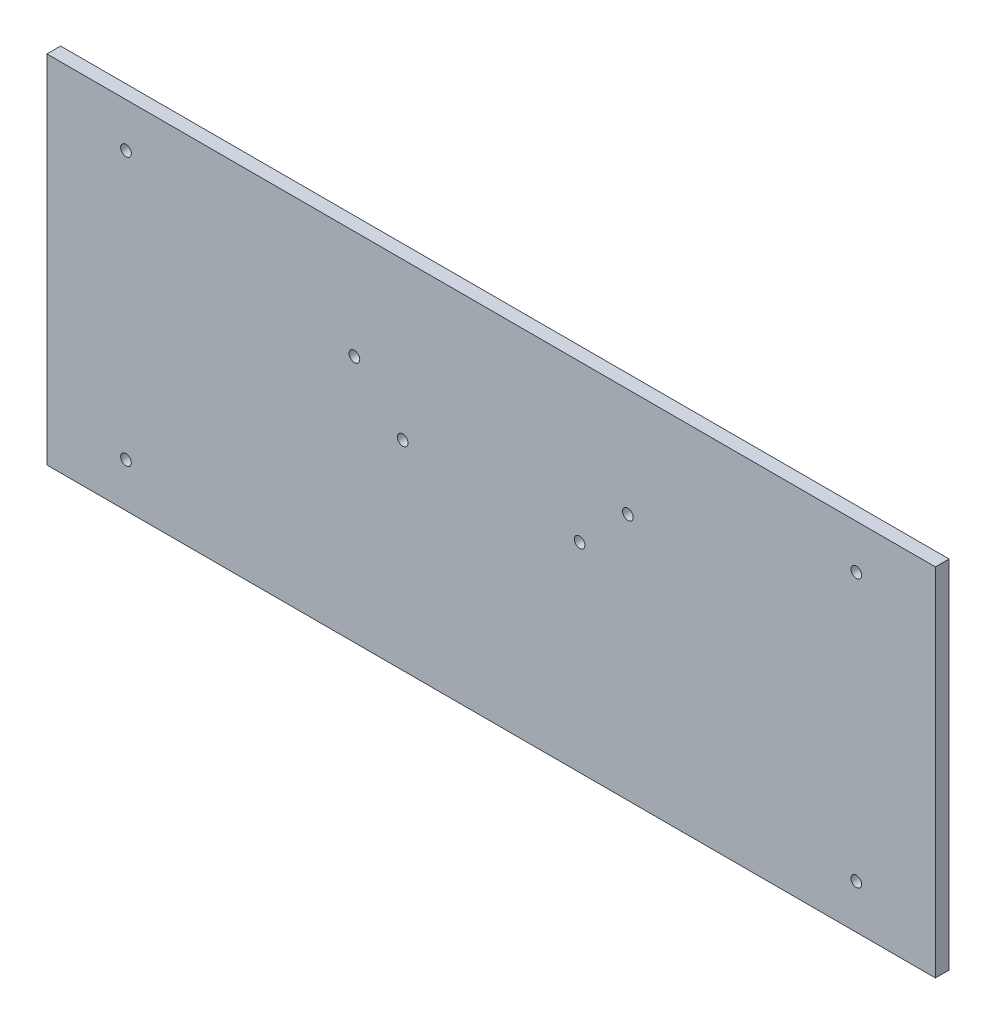
from build123d import *

# Parameters (mm, degrees)
SKETCH1_W               = 292
SKETCH1_H               = 117
BOSS_EXTRUDE1_DEPTH     = 4.5
CUT_EXTRUDE1_REACH      = 159.348
SKETCH1_3_R             = 1.75
MIRROR3_COPY_1_REACH    = 159.348
MIRROR3_COPY_1_SKETCH_R = 1.75
MIRROR3_COPY_2_REACH    = 159.348
MIRROR3_COPY_2_SKETCH_R = 1.75
CUT_EXTRUDE2_REACH      = 159.348
SKETCH2_R               = 1.75


with BuildPart() as part:
    # Sketch1 → Boss-Extrude1 (new body)
    with BuildSketch(Plane.XY):
        Rectangle(SKETCH1_W, SKETCH1_H)
    extrude(amount=BOSS_EXTRUDE1_DEPTH)

    # Sketch1_3 → Cut-Extrude1 (cut, up to next)
    with BuildSketch(Plane.XY, mode=Mode.PRIVATE) as cut_extrude1_sk1:
        with Locations((-120, 44)):
            Circle(SKETCH1_3_R)
    cut_extrude1_tool1 = extrude(cut_extrude1_sk1.sketch, amount=CUT_EXTRUDE1_REACH, mode=Mode.PRIVATE) & part.part
    cut_extrude1 = cut_extrude1_tool1.solids().sort_by_distance((-120, 44, 0))[0]
    add(cut_extrude1, mode=Mode.SUBTRACT)

    # Mirror2: Cut-Extrude1 across plane
    add(cut_extrude1.mirror(Plane.ZX), mode=Mode.SUBTRACT)

    # Mirror3 copy 1 sketch → Mirror3 copy 1 (cut, up to next)
    with BuildSketch(Plane(origin=(0, 0, 0), x_dir=(-1, 0, 0), z_dir=(0, 0, 1)), mode=Mode.PRIVATE) as mirror3_copy_1_sk1:
        with Locations((-120, 44)):
            Circle(MIRROR3_COPY_1_SKETCH_R)
    mirror3_copy_1_tool1 = extrude(mirror3_copy_1_sk1.sketch, amount=MIRROR3_COPY_1_REACH, mode=Mode.PRIVATE) & part.part
    add(mirror3_copy_1_tool1.solids().sort_by_distance((120, -44, 0))[0], mode=Mode.SUBTRACT)

    # Mirror3 copy 2 sketch → Mirror3 copy 2 (cut, up to next)
    with BuildSketch(Plane(origin=(0, 0, 0), x_dir=(-1, 0, 0), z_dir=(0, 0, 1)), mode=Mode.PRIVATE) as mirror3_copy_2_sk1:
        with Locations((-120, -44)):
            Circle(MIRROR3_COPY_2_SKETCH_R)
    mirror3_copy_2_tool1 = extrude(mirror3_copy_2_sk1.sketch, amount=MIRROR3_COPY_2_REACH, mode=Mode.PRIVATE) & part.part
    add(mirror3_copy_2_tool1.solids().sort_by_distance((120, 44, 0))[0], mode=Mode.SUBTRACT)

    # Sketch2 → Cut-Extrude2 (cut, up to next)
    with BuildSketch(Plane.XY.offset(4.5), mode=Mode.PRIVATE) as cut_extrude2_sk1:
        with Locations((-29.071067812, 7.071067812)):
            Circle(SKETCH2_R)
    cut_extrude2_tool1 = extrude(cut_extrude2_sk1.sketch, amount=-CUT_EXTRUDE2_REACH, mode=Mode.PRIVATE) & part.part
    # Sketch2 → Cut-Extrude2 (cut, up to next)
    with BuildSketch(Plane.XY.offset(4.5), mode=Mode.PRIVATE) as cut_extrude2_sk2:
        with Locations((-44.928932188, 22.928932188)):
            Circle(SKETCH2_R)
    cut_extrude2_tool2 = extrude(cut_extrude2_sk2.sketch, amount=-CUT_EXTRUDE2_REACH, mode=Mode.PRIVATE) & part.part
    # Sketch2 → Cut-Extrude2 (cut, up to next)
    with BuildSketch(Plane.XY.offset(4.5), mode=Mode.PRIVATE) as cut_extrude2_sk3:
        with Locations((44.928932188, 22.928932188)):
            Circle(SKETCH2_R)
    cut_extrude2_tool3 = extrude(cut_extrude2_sk3.sketch, amount=-CUT_EXTRUDE2_REACH, mode=Mode.PRIVATE) & part.part
    # Sketch2 → Cut-Extrude2 (cut, up to next)
    with BuildSketch(Plane.XY.offset(4.5), mode=Mode.PRIVATE) as cut_extrude2_sk4:
        with Locations((29.071067812, 7.071067812)):
            Circle(SKETCH2_R)
    cut_extrude2_tool4 = extrude(cut_extrude2_sk4.sketch, amount=-CUT_EXTRUDE2_REACH, mode=Mode.PRIVATE) & part.part
    add(cut_extrude2_tool1.solids().sort_by_distance((-29.071068, 7.071068, 4.5))[0], mode=Mode.SUBTRACT)
    add(cut_extrude2_tool2.solids().sort_by_distance((-44.928932, 22.928932, 4.5))[0], mode=Mode.SUBTRACT)
    add(cut_extrude2_tool3.solids().sort_by_distance((44.928932, 22.928932, 4.5))[0], mode=Mode.SUBTRACT)
    add(cut_extrude2_tool4.solids().sort_by_distance((29.071068, 7.071068, 4.5))[0], mode=Mode.SUBTRACT)


solid = part.part
